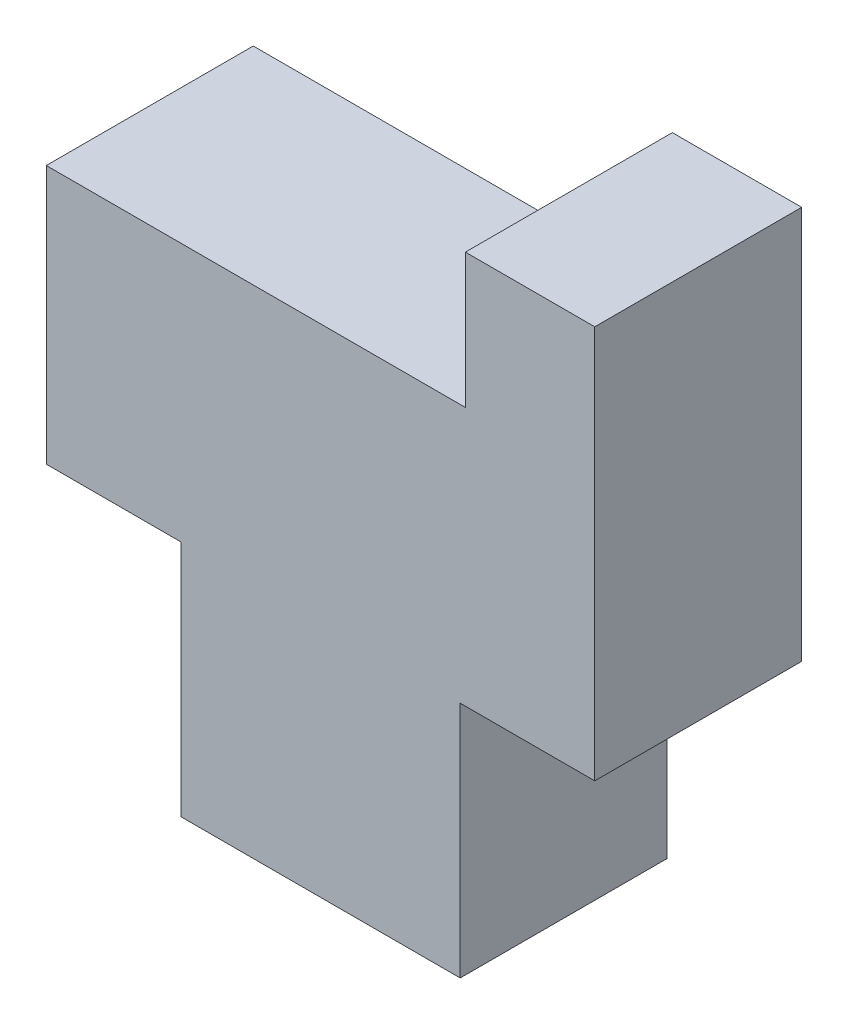
from build123d import *

# Parameters (mm, degrees)
BOSS_EXTRUDE1_DEPTH = 4


with BuildPart() as part:
    # Sketch1 → Boss-Extrude1 (new body)
    with BuildSketch(Plane.XY):
        Polygon((0, 0), (5.4, 0), (5.4, 4.6), (8, 4.6), (8, 12.2), (5.5, 12.2), (5.5, 9.6), (-2.6, 9.6), (-2.6, 4.6), (0, 4.6), align=None)
    extrude(amount=BOSS_EXTRUDE1_DEPTH)


solid = part.part
